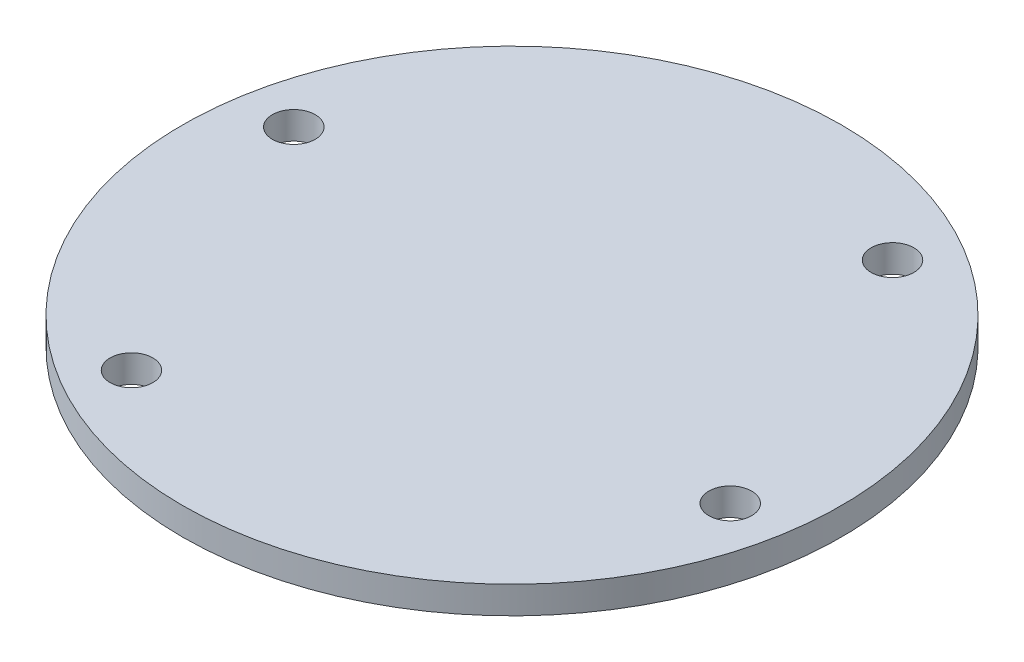
from build123d import *

# Parameters (mm, degrees)
SKETCH1_R           = 19.25
BOSS_EXTRUDE1_DEPTH = 1.6
SKETCH3_R           = 1.25
CUT_EXTRUDE1_DEPTH  = 28.270588553


with BuildPart() as part:
    # Sketch1 → Boss-Extrude1 (new body)
    with BuildSketch(Plane(origin=(0, 0, 0), x_dir=(1, 0, 0), z_dir=(0, 1, 0))):
        Circle(SKETCH1_R)
    extrude(amount=BOSS_EXTRUDE1_DEPTH)

    # Sketch3 → Cut-Extrude1 (cut, through all)
    with BuildSketch(Plane(origin=(0, 1.6, 0), x_dir=(1, 0, 0), z_dir=(0, 1, 0))):
        with Locations((-15.893816823, 3.147175209)):
            Circle(SKETCH3_R)
        with Locations((8.327072013, 13.89884612)):
            Circle(SKETCH3_R)
        with Locations((15.893815137, -3.147176833)):
            Circle(SKETCH3_R)
        with Locations((-8.327794091, -13.899757036)):
            Circle(SKETCH3_R)
    extrude(amount=-CUT_EXTRUDE1_DEPTH, mode=Mode.SUBTRACT)


solid = part.part
